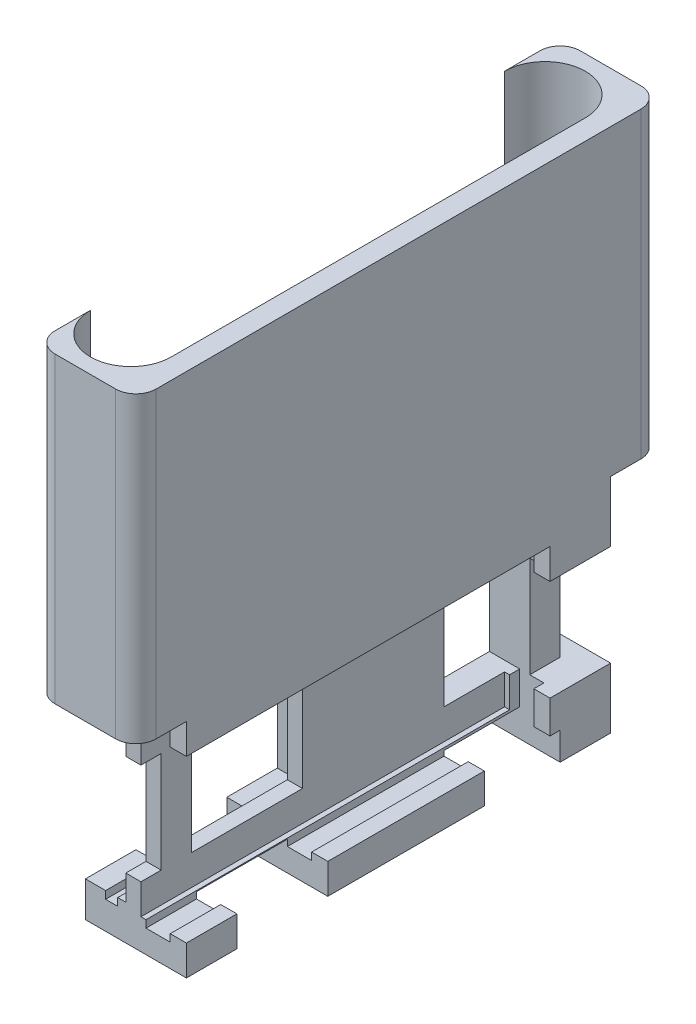
from build123d import *

# Parameters (mm, degrees)
SKETCH1_W           = 10
SKETCH1_H           = 22
BOSS_EXTRUDE1_DEPTH = 42
SKETCH2_W           = 4.5
SKETCH2_H           = 16
CUT_EXTRUDE1_DEPTH  = 36
SKETCH4_W           = 2.4
SKETCH4_H           = 18.2
CUT_EXTRUDE3_DEPTH  = 37
SKETCH5_W           = 4
SKETCH5_H           = 15
CUT_EXTRUDE4_DEPTH  = 19
SKETCH6_W           = 1.2
SKETCH6_H           = 16.5
CUT_EXTRUDE5_DEPTH  = 20.5
SKETCH8_W           = 3
SKETCH8_H           = 14.5
CUT_EXTRUDE6_DEPTH  = 15.5
SKETCH9_W           = 1.2
SKETCH9_H           = 16.5
CUT_EXTRUDE7_DEPTH  = 16.5
SKETCH10_W          = 12
SKETCH10_H          = 16
CUT_EXTRUDE8_DEPTH  = 2.5
SKETCH12_W          = 9
SKETCH12_H          = 2.9
SKETCH12_W_2        = 7.5
SKETCH12_H_2        = 2.75
CUT_EXTRUDE11_DEPTH = 10
CUT_EXTRUDE12_REACH = 12
SKETCH13_W          = 9
SKETCH13_H          = 0.6
SKETCH13_W_2        = 7.5
SKETCH13_H_2        = 0.25
CUT_EXTRUDE13_REACH = 12
SKETCH14_W          = 9
SKETCH14_H          = 0.1
SKETCH14_W_2        = 6.5
SKETCH14_H_2        = 0.25
SKETCH15_W          = 2
SKETCH15_H          = 10
SKETCH15_W_2        = 11
CUT_EXTRUDE14_DEPTH = 7
SKETCH16_W          = 2
SKETCH16_H          = 10
SKETCH16_W_2        = 7
CUT_EXTRUDE15_DEPTH = 10
SKETCH17_W          = 3
SKETCH17_H          = 10
CUT_EXTRUDE16_DEPTH = 10
SKETCH18_W          = 10
SKETCH18_H          = 52
BOSS_EXTRUDE3_DEPTH = 30
SKETCH21_W          = 1.3
SKETCH21_H          = 6
CUT_EXTRUDE18_DEPTH = 28
FILLET1_R           = 2
FILLET3_R           = 1
CUT_EXTRUDE19_DEPTH = 28
FILLET4_R           = 2


with BuildPart() as part:
    # Sketch1 → Boss-Extrude1 (new body)
    with BuildSketch(Plane.XY):
        Rectangle(SKETCH1_W, SKETCH1_H)
    extrude(amount=BOSS_EXTRUDE1_DEPTH)

    # Sketch2 → Cut-Extrude1 (cut)
    with BuildSketch(Plane.XY.offset(42)):
        with Locations((2.75, 0)):
            Rectangle(SKETCH2_W, SKETCH2_H)
    extrude(amount=-CUT_EXTRUDE1_DEPTH, mode=Mode.SUBTRACT)

    # Sketch4 → Cut-Extrude3 (cut)
    with BuildSketch(Plane.XY.offset(42)):
        with Locations((2.2, 0.373327294)):
            Rectangle(SKETCH4_W, SKETCH4_H)
    extrude(amount=-CUT_EXTRUDE3_DEPTH, mode=Mode.SUBTRACT)

    # Sketch5 → Cut-Extrude4 (cut)
    with BuildSketch(Plane.XY.offset(42)):
        with Locations((-3, 0)):
            Rectangle(SKETCH5_W, SKETCH5_H)
    extrude(amount=-CUT_EXTRUDE4_DEPTH, mode=Mode.SUBTRACT)

    # Sketch6 → Cut-Extrude5 (cut)
    with BuildSketch(Plane.XY.offset(42)):
        with Locations((-2.4, 0)):
            Rectangle(SKETCH6_W, SKETCH6_H)
    extrude(amount=-CUT_EXTRUDE5_DEPTH, mode=Mode.SUBTRACT)

    # Sketch8 → Cut-Extrude6 (cut)
    with BuildSketch(Plane(origin=(0, 0, 0), x_dir=(-1, 0, 0), z_dir=(0, 0, -1))):
        with Locations((3.5, 0)):
            Rectangle(SKETCH8_W, SKETCH8_H)
    extrude(amount=-CUT_EXTRUDE6_DEPTH, mode=Mode.SUBTRACT)

    # Sketch9 → Cut-Extrude7 (cut)
    with BuildSketch(Plane(origin=(0, 0, 0), x_dir=(-1, 0, 0), z_dir=(0, 0, -1))):
        with Locations((3.1, 0)):
            Rectangle(SKETCH9_W, SKETCH9_H)
    extrude(amount=-CUT_EXTRUDE7_DEPTH, mode=Mode.SUBTRACT)

    # Sketch10 → Cut-Extrude8 (cut)
    with BuildSketch(Plane.ZY.offset(5)):
        with Locations((8, 0)):
            Rectangle(SKETCH10_W, SKETCH10_H)
    extrude(amount=-CUT_EXTRUDE8_DEPTH, mode=Mode.SUBTRACT)

    # Sketch12 → Cut-Extrude11 (cut)
    with BuildSketch(Plane.ZY.offset(5)):
        with Locations((32.5, -9.55)):
            Rectangle(SKETCH12_W, SKETCH12_H)
        with Locations((8.75, -9.625)):
            Rectangle(SKETCH12_W_2, SKETCH12_H_2)
    extrude(amount=-CUT_EXTRUDE11_DEPTH, mode=Mode.SUBTRACT)

    # Sketch13 → Cut-Extrude12 (cut, up to next)
    with BuildSketch(Plane.ZY.offset(5), mode=Mode.PRIVATE) as cut_extrude12_sk1:
        with Locations((32.5, -7.8)):
            Rectangle(SKETCH13_W, SKETCH13_H)
    cut_extrude12_tool1 = extrude(cut_extrude12_sk1.sketch, amount=-CUT_EXTRUDE12_REACH, mode=Mode.PRIVATE) & part.part
    add(cut_extrude12_tool1.solids().sort_by_distance((-5, -7.8, 32.5))[0], mode=Mode.SUBTRACT)
    # Sketch13 → Cut-Extrude12 (cut, up to next)
    with BuildSketch(Plane.ZY.offset(5), mode=Mode.PRIVATE) as cut_extrude12_sk2:
        with Locations((8.75, -8.125)):
            Rectangle(SKETCH13_W_2, SKETCH13_H_2)
    cut_extrude12_tool2 = extrude(cut_extrude12_sk2.sketch, amount=-CUT_EXTRUDE12_REACH, mode=Mode.PRIVATE) & part.part
    add(cut_extrude12_tool2.solids().sort_by_distance((-5, -8.125, 8.75))[0], mode=Mode.SUBTRACT)

    # Sketch14 → Cut-Extrude13 (cut, up to next)
    with BuildSketch(Plane(origin=(5, 0, 0), x_dir=(0, 0, -1), z_dir=(1, 0, 0)), mode=Mode.PRIVATE) as cut_extrude13_sk1:
        with Locations((-32.5, -8.05)):
            Rectangle(SKETCH14_W, SKETCH14_H)
    cut_extrude13_tool1 = extrude(cut_extrude13_sk1.sketch, amount=-CUT_EXTRUDE13_REACH, mode=Mode.PRIVATE) & part.part
    add(cut_extrude13_tool1.solids().sort_by_distance((5, -8.05, 32.5))[0], mode=Mode.SUBTRACT)
    # Sketch14 → Cut-Extrude13 (cut, up to next)
    with BuildSketch(Plane(origin=(5, 0, 0), x_dir=(0, 0, -1), z_dir=(1, 0, 0)), mode=Mode.PRIVATE) as cut_extrude13_sk2:
        with Locations((-9.25, -8.125)):
            Rectangle(SKETCH14_W_2, SKETCH14_H_2)
    cut_extrude13_tool2 = extrude(cut_extrude13_sk2.sketch, amount=-CUT_EXTRUDE13_REACH, mode=Mode.PRIVATE) & part.part
    add(cut_extrude13_tool2.solids().sort_by_distance((5, -8.125, 9.25))[0], mode=Mode.SUBTRACT)

    # Sketch15 → Cut-Extrude14 (cut, through all)
    with BuildSketch(Plane.ZY.offset(1)):
        with Locations((41, 0)):
            Rectangle(SKETCH15_W, SKETCH15_H)
        with Locations((31.5, 0)):
            Rectangle(SKETCH15_W_2, SKETCH15_H)
    extrude(amount=-CUT_EXTRUDE14_DEPTH, mode=Mode.SUBTRACT)

    # Sketch16 → Cut-Extrude15 (cut)
    with BuildSketch(Plane.ZY.offset(2)):
        with Locations((1, 0)):
            Rectangle(SKETCH16_W, SKETCH16_H)
        with Locations((8.5, 0)):
            Rectangle(SKETCH16_W_2, SKETCH16_H)
    extrude(amount=-CUT_EXTRUDE15_DEPTH, mode=Mode.SUBTRACT)

    # Sketch17 → Cut-Extrude16 (cut)
    with BuildSketch(Plane(origin=(0, 0, 2), x_dir=(-1, 0, 0), z_dir=(0, 0, -1))):
        with Locations((-3.5, 0)):
            Rectangle(SKETCH17_W, SKETCH17_H)
    extrude(amount=-CUT_EXTRUDE16_DEPTH, mode=Mode.SUBTRACT)

    # Sketch18 → Boss-Extrude3 (add)
    with BuildSketch(Plane(origin=(0, 11, 0), x_dir=(1, 0, 0), z_dir=(0, 1, 0))):
        with Locations((0, -21)):
            Rectangle(SKETCH18_W, SKETCH18_H)
    extrude(amount=BOSS_EXTRUDE3_DEPTH)

    # Sketch21 → Cut-Extrude18 (cut)
    with BuildSketch(Plane.XZ.offset(-8)):
        with Locations((-4.35, 9)):
            Rectangle(SKETCH21_W, SKETCH21_H)
    extrude(amount=-CUT_EXTRUDE18_DEPTH, mode=Mode.SUBTRACT)

    # Fillet1
    fillet1_edges = [part.edges().sort_by_distance(p)[0] for p in [
        (5, 26, -5),
        (-5, 26, -5),
        (5, 26, 47),
        (-5, 26, 47),
    ]]
    fillet(fillet1_edges, radius=FILLET1_R)

    # Fillet3
    fillet3_edges = [part.edges().sort_by_distance(p)[0] for p in [
        (-3.7, 8.25, 9),
    ]]
    fillet(fillet3_edges, radius=FILLET3_R)

    # Sketch22 → Cut-Extrude19 (cut)
    with BuildSketch(Plane(origin=(0, 41, 0), x_dir=(1, 0, 0), z_dir=(0, 1, 0))):
        with BuildLine():
            Line((-5, -41.5), (-5, -0.5))
            ThreePointArc((-5, -0.5), (-1, 3.5), (3, -0.5))
            Line((3, -0.5), (3, -41.5))
            ThreePointArc((3, -41.5), (-1, -45.5), (-5, -41.5))
        make_face()
    extrude(amount=-CUT_EXTRUDE19_DEPTH, mode=Mode.SUBTRACT)

    # Fillet4
    fillet4_edges = [part.edges().sort_by_distance(p)[0] for p in [
        (-3.7, 13, 9),
    ]]
    fillet(fillet4_edges, radius=FILLET4_R)


solid = part.part
